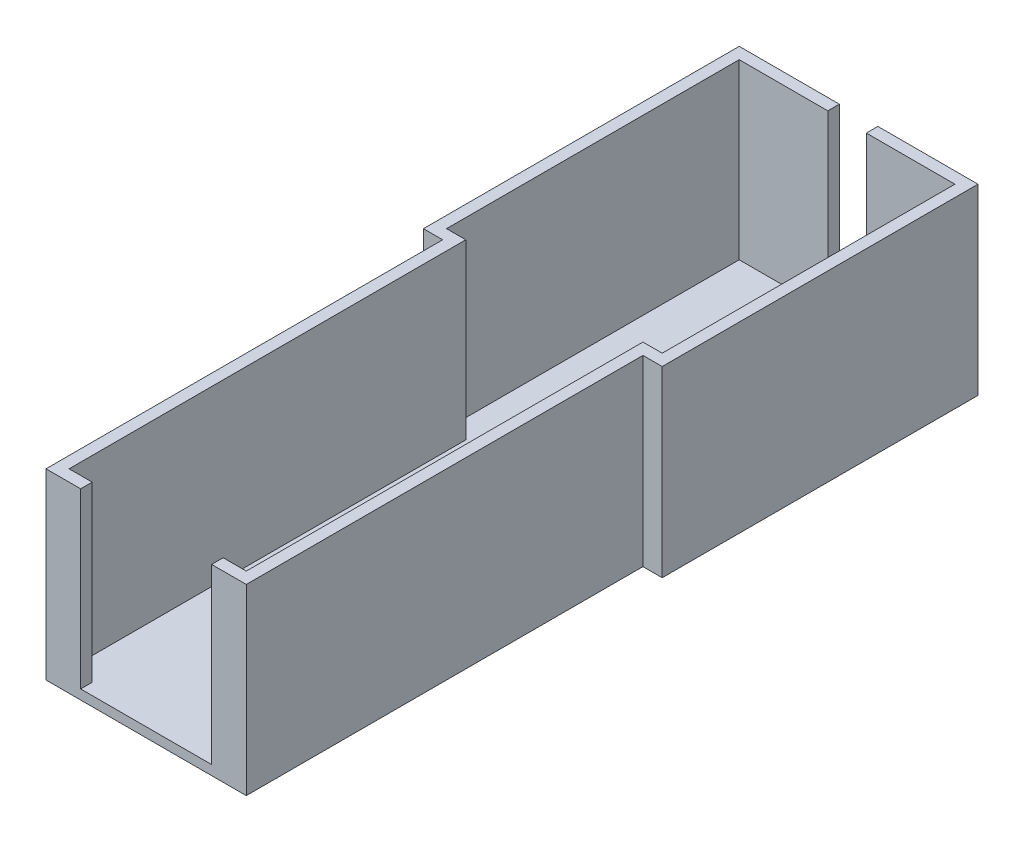
from build123d import *

# Parameters (mm, degrees)
SKETCH1_W           = 52
SKETCH1_H           = 103
SKETCH1_W_2         = 62
SKETCH1_H_2         = 82
BOSS_EXTRUDE1_DEPTH = 2.5
SKETCH2_W           = 3
SKETCH2_H           = 100
SKETCH2_H_2         = 76
SKETCH2_W_2         = 2
SKETCH2_H_3         = 3
SKETCH2_W_3         = 56
SKETCH2_W_4         = 46
BOSS_EXTRUDE2_DEPTH = 45
SKETCH4_W           = 10
SKETCH4_H           = 3
SKETCH4_W_2         = 34
CUT_EXTRUDE1_DEPTH  = 45


with BuildPart() as part:
    # Sketch1 → Boss-Extrude1 (new body)
    with BuildSketch(Plane(origin=(0, 0, 0), x_dir=(1, 0, 0), z_dir=(0, 1, 0))):
        with Locations((0.405405405, -109.013513514)):
            Rectangle(SKETCH1_W, SKETCH1_H)
        with Locations((0.405405405, -16.513513514)):
            Rectangle(SKETCH1_W_2, SKETCH1_H_2)
    extrude(amount=BOSS_EXTRUDE1_DEPTH)

    # Sketch2 → Boss-Extrude2 (add)
    with BuildSketch(Plane(origin=(0, 2.5, 0), x_dir=(1, 0, 0), z_dir=(0, 1, 0))):
        with Locations((-24.094594595, -107.513513514)):
            Rectangle(SKETCH2_W, SKETCH2_H)
        with Locations((24.905405405, -107.513513514)):
            Rectangle(SKETCH2_W, SKETCH2_H)
        with Locations((29.905405405, -16.513513514)):
            Rectangle(SKETCH2_W, SKETCH2_H_2)
        with Locations((-29.094594595, -16.513513514)):
            Rectangle(SKETCH2_W, SKETCH2_H_2)
        with Locations((-26.594594595, -56.013513514)):
            Rectangle(SKETCH2_W_2, SKETCH2_H_3)
        with Locations((-24.094594595, -56.013513514)):
            Rectangle(SKETCH2_W, SKETCH2_H_3)
        with Locations((-29.094594595, -56.013513514)):
            Rectangle(SKETCH2_W, SKETCH2_H_3)
        with Locations((29.905405405, -56.013513514)):
            Rectangle(SKETCH2_W, SKETCH2_H_3)
        with Locations((27.405405405, -56.013513514)):
            Rectangle(SKETCH2_W_2, SKETCH2_H_3)
        with Locations((24.905405405, -56.013513514)):
            Rectangle(SKETCH2_W, SKETCH2_H_3)
        with Locations((-29.094594595, 22.986486486)):
            Rectangle(SKETCH2_W, SKETCH2_H_3)
        with Locations((29.905405405, 22.986486486)):
            Rectangle(SKETCH2_W, SKETCH2_H_3)
        with Locations((0.405405405, 22.986486486)):
            Rectangle(SKETCH2_W_3, SKETCH2_H_3)
        with Locations((-24.094594595, -159.013513514)):
            Rectangle(SKETCH2_W, SKETCH2_H_3)
        with Locations((0.405405405, -159.013513514)):
            Rectangle(SKETCH2_W_4, SKETCH2_H_3)
        with Locations((24.905405405, -159.013513514)):
            Rectangle(SKETCH2_W, SKETCH2_H_3)
    extrude(amount=BOSS_EXTRUDE2_DEPTH)

    # Sketch4 → Cut-Extrude1 (cut)
    with BuildSketch(Plane(origin=(0, 47.5, 0), x_dir=(1, 0, 0), z_dir=(0, 1, 0))):
        with Locations((0.405405405, 22.986486486)):
            Rectangle(SKETCH4_W, SKETCH4_H)
        with Locations((0.405405405, -159.013513514)):
            Rectangle(SKETCH4_W_2, SKETCH4_H)
    extrude(amount=-CUT_EXTRUDE1_DEPTH, mode=Mode.SUBTRACT)


solid = part.part
